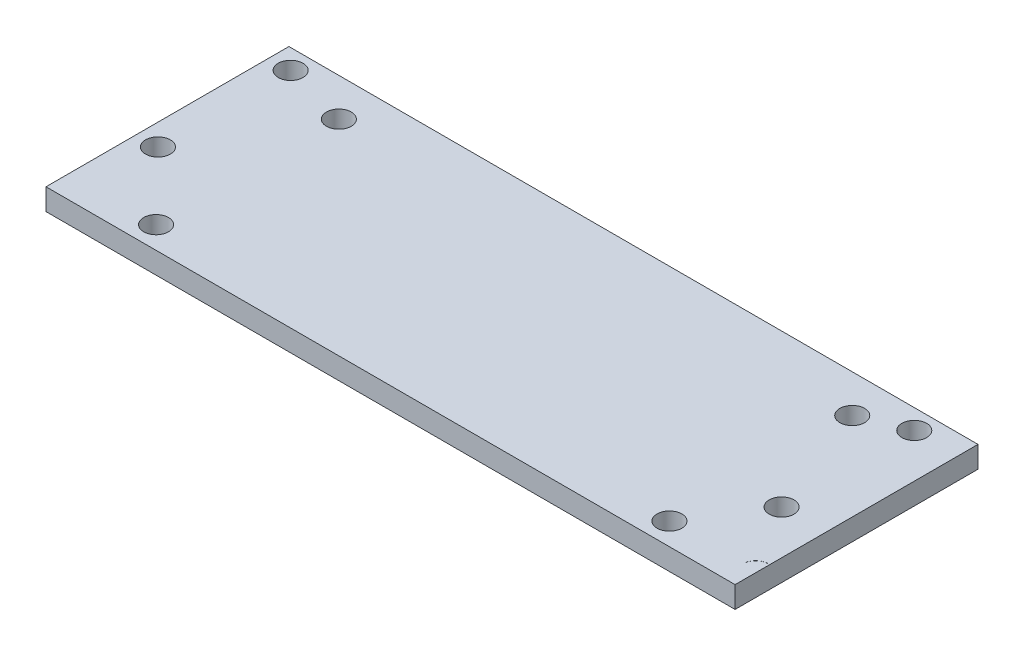
from build123d import *

# Parameters (mm, degrees)
SKETCH1_W           = 114.3
SKETCH1_H           = 35.814
BOSS_EXTRUDE1_DEPTH = 3.175
SKETCH3_R           = 1.8288
CUT_EXTRUDE2_DEPTH  = 4.175
SKETCH4_W           = 12.7
SKETCH4_H           = 35.814
CUT_EXTRUDE3_DEPTH  = 4.175
SKETCH5_R           = 1.8288
CUT_EXTRUDE4_DEPTH  = 4.175
BOSS_EXTRUDE4_DEPTH = 3.175
SKETCH9_R           = 1.8288
CUT_EXTRUDE5_DEPTH  = 4.175
BOSS_EXTRUDE5_DEPTH = 3.175


with BuildPart() as part:
    # Sketch1 → Boss-Extrude1 (new body)
    with BuildSketch(Plane(origin=(0, 0, 0), x_dir=(1, 0, 0), z_dir=(0, 1, 0))):
        Rectangle(SKETCH1_W, SKETCH1_H)
    extrude(amount=BOSS_EXTRUDE1_DEPTH)

    # Sketch3 → Cut-Extrude2 (cut, through all)
    with BuildSketch(Plane(origin=(0, 3.175, 0), x_dir=(1, 0, 0), z_dir=(0, 1, 0))):
        with Locations((-53.975, 14.986)):
            Circle(SKETCH3_R)
        with Locations((-53.975, -4.572)):
            Circle(SKETCH3_R)
        with Locations((-44.196, 12.319)):
            Circle(SKETCH3_R)
        with Locations((-44.196, -14.6304)):
            Circle(SKETCH3_R)
        with Locations((44.196, -14.6304)):
            Circle(SKETCH3_R)
        with Locations((53.975, -4.572)):
            Circle(SKETCH3_R)
        with Locations((44.196, 12.319)):
            Circle(SKETCH3_R)
        with Locations((53.975, 14.986)):
            Circle(SKETCH3_R)
    extrude(amount=-CUT_EXTRUDE2_DEPTH, mode=Mode.SUBTRACT)

    # Sketch4 → Cut-Extrude3 (cut, through all)
    with BuildSketch(Plane(origin=(0, 3.175, 0), x_dir=(1, 0, 0), z_dir=(0, 1, 0))):
        with Locations((50.8, 0)):
            Rectangle(SKETCH4_W, SKETCH4_H)
    extrude(amount=-CUT_EXTRUDE3_DEPTH, mode=Mode.SUBTRACT)

    # Sketch5 → Cut-Extrude4 (cut, through all)
    with BuildSketch(Plane(origin=(0, 3.175, 0), x_dir=(1, 0, 0), z_dir=(0, 1, 0))):
        with Locations((-44.196, 12.319)):
            Circle(SKETCH5_R)
        with Locations((-53.975, 14.986)):
            Circle(SKETCH5_R)
        with Locations((-53.975, -4.572)):
            Circle(SKETCH5_R)
        with Locations((-44.196, -14.6304)):
            Circle(SKETCH5_R)
        with Locations((31.496, -14.6304)):
            Circle(SKETCH5_R)
        with Locations((41.275, -4.572)):
            Circle(SKETCH5_R)
        with Locations((31.496, 12.319)):
            Circle(SKETCH5_R)
        with Locations((41.275, 14.986)):
            Circle(SKETCH5_R)
    extrude(amount=-CUT_EXTRUDE4_DEPTH, mode=Mode.SUBTRACT)

    # Sketch8 → Boss-Extrude4 (add)
    with BuildSketch(Plane(origin=(0, 3.175, 0), x_dir=(1, 0, 0), z_dir=(0, 1, 0))):
        with BuildLine():
            Line((44.196, 14.1478), (44.45, 14.542460619))
            Line((44.45, 14.542460619), (44.45, 10.507924783))
            ThreePointArc((44.45, 10.507924783), (42.371636577, 12.191691155), (44.196, 14.1478))
        make_face()
        with BuildLine():
            Line((44.196, -12.8016), (44.45, -12.55116419))
            Line((44.45, -12.55116419), (44.45, -16.7132))
            Line((44.45, -16.7132), (44.323, -16.5862))
            ThreePointArc((44.323, -16.5862), (42.3672, -14.7574), (44.196, -12.8016))
        make_face()
    extrude(amount=-BOSS_EXTRUDE4_DEPTH)

    # Sketch9 → Cut-Extrude5 (cut, through all)
    with BuildSketch(Plane(origin=(0, 3.175, 0), x_dir=(1, 0, 0), z_dir=(0, 1, 0))):
        with Locations((37.973, -4.572)):
            Circle(SKETCH9_R)
        with Locations((37.973, 14.986)):
            Circle(SKETCH9_R)
    extrude(amount=-CUT_EXTRUDE5_DEPTH, mode=Mode.SUBTRACT)

    # Sketch10 → Boss-Extrude5 (add)
    with BuildSketch(Plane(origin=(0, 3.175, 0), x_dir=(1, 0, 0), z_dir=(0, 1, 0))):
        with BuildLine():
            ThreePointArc((39.624, 14.199419782), (39.8018, 14.986), (39.624, 15.772580218))
            ThreePointArc((39.624, 15.772580218), (43.1038, 14.986), (39.624, 14.199419782))
        make_face()
        with BuildLine():
            ThreePointArc((39.624, -5.358580218), (39.8018, -4.572), (39.624, -3.785419782))
            ThreePointArc((39.624, -3.785419782), (43.1038, -4.572), (39.624, -5.358580218))
        make_face()
    extrude(amount=-BOSS_EXTRUDE5_DEPTH)


solid = part.part
